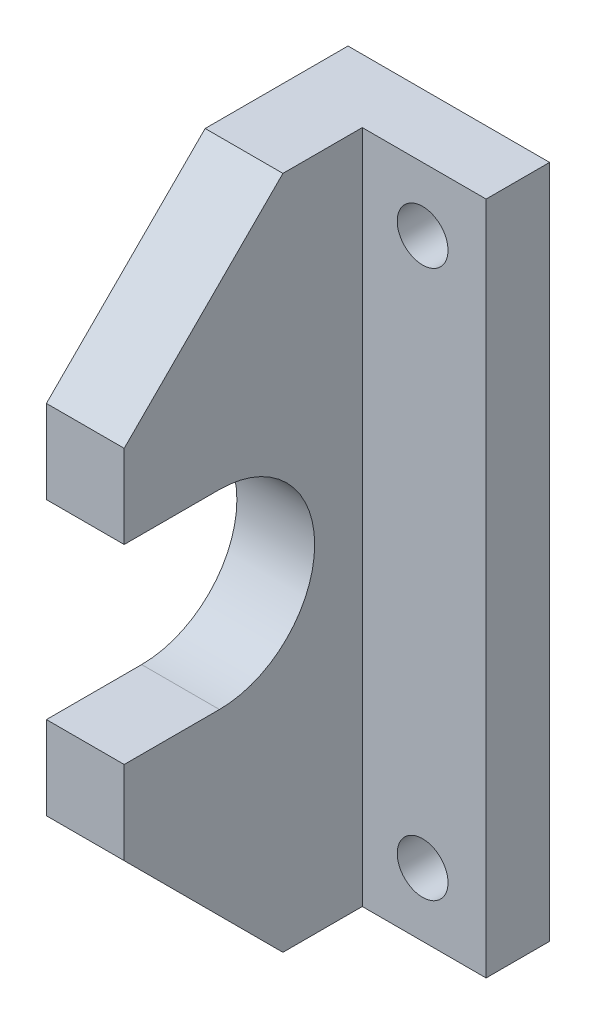
from build123d import *

# Parameters (mm, degrees)
ESQUISSE1_W             = 12.7
ESQUISSE1_H             = 42.5
ESQUISSE1_R             = 1.6
BOSS_EXTRU_1_DEPTH      = 4
ESQUISSE2_W             = 4.9
ESQUISSE2_H             = 42.5
BOSS_EXTRU_2_DEPTH      = 15
ENL_V_MAT_EXTRU_1_DEPTH = 5.9
CHANFREIN1_SIZE         = 10


with BuildPart() as part:
    # Esquisse1 → Boss.-Extru.1 (new body)
    with BuildSketch(Plane.XY):
        with Locations((32.265489842, 21.249999998)):
            Rectangle(ESQUISSE1_W, ESQUISSE1_H)
        with Locations((34.615489842, 3.999999998)):
            Circle(ESQUISSE1_R, mode=Mode.SUBTRACT)
        with Locations((34.615489842, 38.499999998)):
            Circle(ESQUISSE1_R, mode=Mode.SUBTRACT)
    extrude(amount=BOSS_EXTRU_1_DEPTH)

    # Esquisse2 → Boss.-Extru.2 (add)
    with BuildSketch(Plane.XY.offset(4)):
        with Locations((28.365489842, 21.249999998)):
            Rectangle(ESQUISSE2_W, ESQUISSE2_H)
    extrude(amount=BOSS_EXTRU_2_DEPTH)

    # Esquisse3 → Enlèv. mat.-Extru.1 (cut, through all)
    with BuildSketch(Plane(origin=(30.815489842, 0, 0), x_dir=(0, 0, -1), z_dir=(1, 0, 0))):
        with BuildLine():
            Line((-13, 27.250000431), (-19, 27.250000431))
            Line((-19, 27.250000431), (-19, 15.250000431))
            Line((-19, 15.250000431), (-13, 15.250000431))
            ThreePointArc((-13, 15.250000431), (-7, 21.250000431), (-13, 27.250000431))
        make_face()
    extrude(amount=-ENL_V_MAT_EXTRU_1_DEPTH, mode=Mode.SUBTRACT)

    # Chanfrein1
    chanfrein1_edges = [part.edges().sort_by_distance(p)[0] for p in [
        (28.365489842, 42.499999998, 19),
        (28.365489842, -2e-09, 19),
    ]]
    chamfer(chanfrein1_edges, length=CHANFREIN1_SIZE)


solid = part.part
